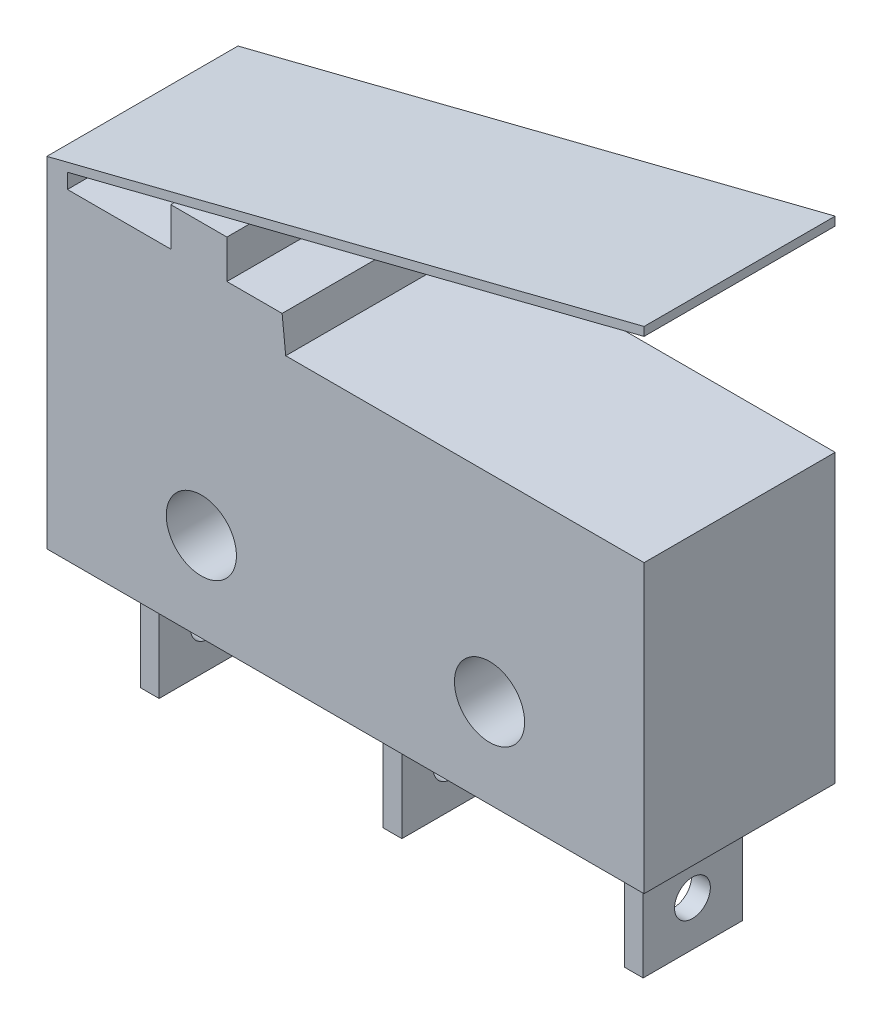
from build123d import *

# Parameters (mm, degrees)
ESQUISSE1_W             = 20
ESQUISSE1_H             = 9.6
BOSS_EXTRU_1_DEPTH      = 6.4
ESQUISSE2_R             = 1.175
ENL_V_MAT_EXTRU_1_DEPTH = 6.4
BOSS_EXTRU_66_DEPTH     = 6.4
ESQUISSE5_W             = 0.63
ESQUISSE5_H             = 3.33
BOSS_EXTRU_67_DEPTH     = 4.01
ESQUISSE6_R             = 0.6
ENL_V_MAT_EXTRU_2_DEPTH = 19.01


with BuildPart() as part:
    # Esquisse1 → Boss.-Extru.1 (new body)
    with BuildSketch(Plane.XY):
        with Locations((11.361848554, 25.841592458)):
            Rectangle(ESQUISSE1_W, ESQUISSE1_H)
    extrude(amount=BOSS_EXTRU_1_DEPTH)

    # Esquisse2 → Enlèv. mat.-Extru.1 (cut)
    with BuildSketch(Plane.XY.offset(6.4)):
        with Locations((16.186848554, 24.016592458)):
            Circle(ESQUISSE2_R)
        with Locations((6.536848554, 24.016592458)):
            Circle(ESQUISSE2_R)
    extrude(amount=-ENL_V_MAT_EXTRU_1_DEPTH, mode=Mode.SUBTRACT)

    # Esquisse4 → Boss.-Extru.66 (add)
    with BuildSketch(Plane.XY.offset(6.4)):
        Polygon((1.361848554, 32.424730159), (1.361848554, 30.641592458), (9.361848554, 30.641592458), (9.24123613, 31.809658088), (7.392325504, 31.809658088), (7.392325504, 33.099658088), (5.512325504, 33.099658088), (5.512325504, 31.809658088), (2.052325504, 31.809658088), (2.052325504, 32.309658088), (21.361848554, 37.201602535), (21.361848554, 37.491602535), align=None)
    extrude(amount=-BOSS_EXTRU_66_DEPTH)

    # Esquisse5 → Boss.-Extru.67 (add)
    with BuildSketch(Plane.XZ.offset(-21.041592458)):
        with Locations((3.256848554, 3.185)):
            Rectangle(ESQUISSE5_W, ESQUISSE5_H)
        with Locations((11.386848554, 3.185)):
            Rectangle(ESQUISSE5_W, ESQUISSE5_H)
        with Locations((19.466848554, 3.185)):
            Rectangle(ESQUISSE5_W, ESQUISSE5_H)
    extrude(amount=BOSS_EXTRU_67_DEPTH)

    # Esquisse6 → Enlèv. mat.-Extru.2 (cut)
    with BuildSketch(Plane.ZY.offset(-2.941848554)):
        with Locations((3.2, 18.531592458)):
            Circle(ESQUISSE6_R)
    extrude(amount=-ENL_V_MAT_EXTRU_2_DEPTH, mode=Mode.SUBTRACT)


solid = part.part
